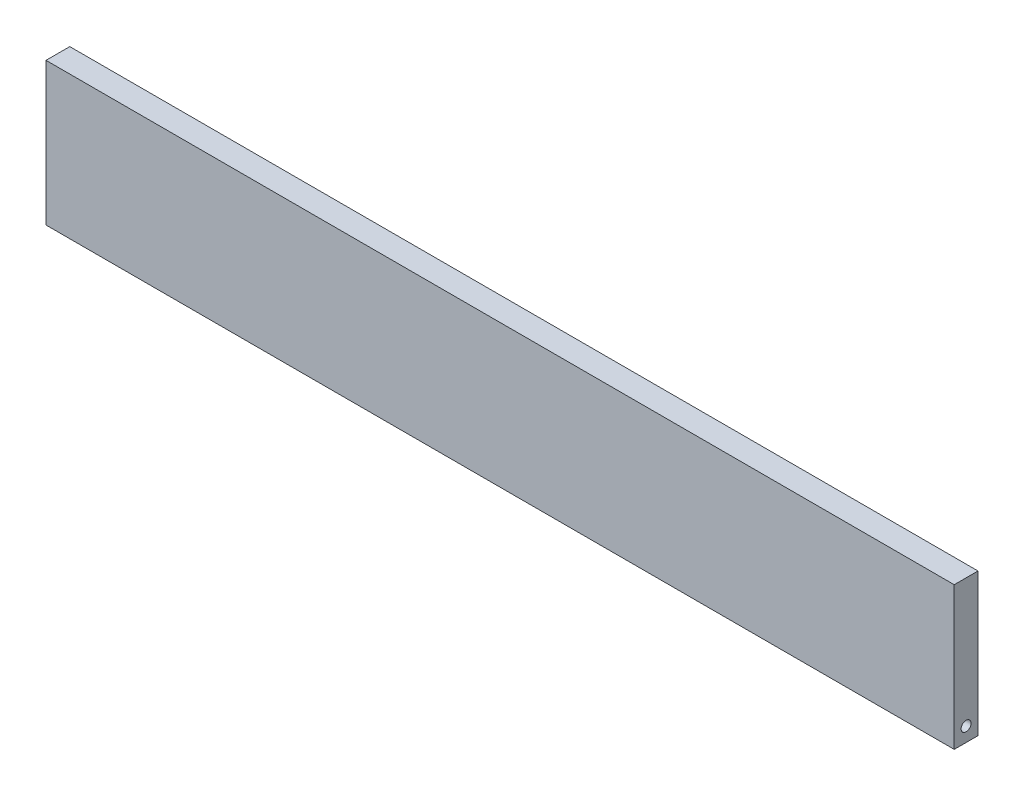
from build123d import *

# Parameters (mm, degrees)
ESQUISSE1_W                = 191
ESQUISSE1_H                = 30
BOSS_EXTRU_1_DEPTH         = 5
ESQUISSE3_R                = 1.05
ENL_V_MAT_EXTRU_5_DEPTH    = 10
R_P_TITION_LIN_AIRE1_COUNT = 2
R_P_TITION_LIN_AIRE1_PITCH = 181


with BuildPart() as part:
    # Esquisse1 → Boss.-Extru.1 (new body)
    with BuildSketch(Plane.XY):
        with Locations((7.157177791, -31.374242424)):
            Rectangle(ESQUISSE1_W, ESQUISSE1_H)
    extrude(amount=BOSS_EXTRU_1_DEPTH)

    # Esquisse3 → Enlèv. mat.-Extru.5 (cut)
    with BuildSketch(Plane(origin=(102.657177791, 0, 0), x_dir=(0, 0, -1), z_dir=(1, 0, 0))):
        with Locations((-2.5, -43.374242424)):
            Circle(ESQUISSE3_R)
    enl_v_mat_extru_5 = extrude(amount=-ENL_V_MAT_EXTRU_5_DEPTH, mode=Mode.SUBTRACT)

    # Répétition linéaire1: Enlèv. mat.-Extru.5 ×2
    with Locations(*[(-i * R_P_TITION_LIN_AIRE1_PITCH, 0, 0) for i in range(1, R_P_TITION_LIN_AIRE1_COUNT)]):
        add(enl_v_mat_extru_5, mode=Mode.SUBTRACT)


solid = part.part
